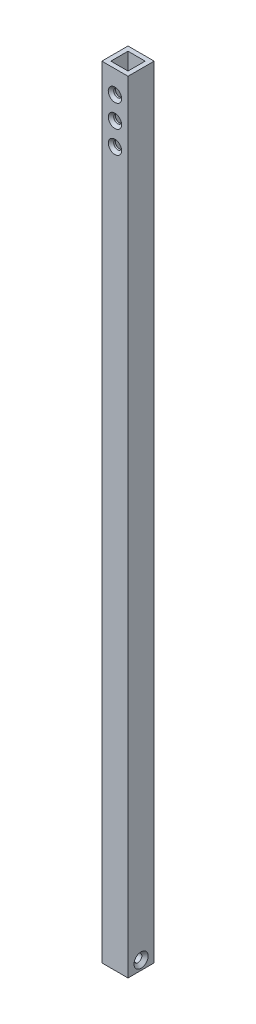
from build123d import *

# Parameters (mm, degrees)
SKETCH1_W           = 18.46
SKETCH1_H           = 18.46
SKETCH1_W_2         = 12.11
SKETCH1_H_2         = 12.11
BOSS_EXTRUDE1_DEPTH = 550.5
SKETCH2_W           = 12.11
SKETCH2_H           = 12.11
BOSS_EXTRUDE2_DEPTH = 12.7
LPATTERN1_COUNT     = 3
LPATTERN1_PITCH     = 15.9


with BuildPart() as part:
    # Sketch1 → Boss-Extrude1 (new body)
    with BuildSketch(Plane(origin=(0, 0, 0), x_dir=(1, 0, 0), z_dir=(0, 1, 0))):
        Rectangle(SKETCH1_W, SKETCH1_H)
        Rectangle(SKETCH1_W_2, SKETCH1_H_2, mode=Mode.SUBTRACT)
    extrude(amount=BOSS_EXTRUDE1_DEPTH)

    # Sketch2 → Boss-Extrude2 (add)
    with BuildSketch(Plane.XZ):
        Rectangle(SKETCH2_W, SKETCH2_H)
    extrude(amount=-BOSS_EXTRUDE2_DEPTH)

    # Sketch4 → Cut-Revolve1 (revolve, cut)
    with BuildSketch(Plane.XY):
        Polygon((-9.23, 6.365), (9.23, 6.365), (9.23, 1.365), (7.005, 3.59), (-9.23, 3.59), align=None)
    revolve(axis=Axis((-9.23, 6.365, 0), (1, 0, 0)), mode=Mode.SUBTRACT)

    # Sketch5 → Cut-Revolve2 (revolve, cut)
    with BuildSketch(Plane(origin=(0, 0, 0), x_dir=(0, 0, -1), z_dir=(1, 0, 0))):
        Polygon((-7.305, 537.35), (-9.23, 539.275), (-9.23, 534.575), (9.23, 534.575), (9.23, 537.35), align=None)
    cut_revolve2 = revolve(axis=Axis((0, 534.575, 9.23), (0, 0, 1)), mode=Mode.SUBTRACT)

    # LPattern1: Cut-Revolve2 ×3
    with Locations(*[(0, -i * LPATTERN1_PITCH, 0) for i in range(1, LPATTERN1_COUNT)]):
        add(cut_revolve2, mode=Mode.SUBTRACT)


solid = part.part
